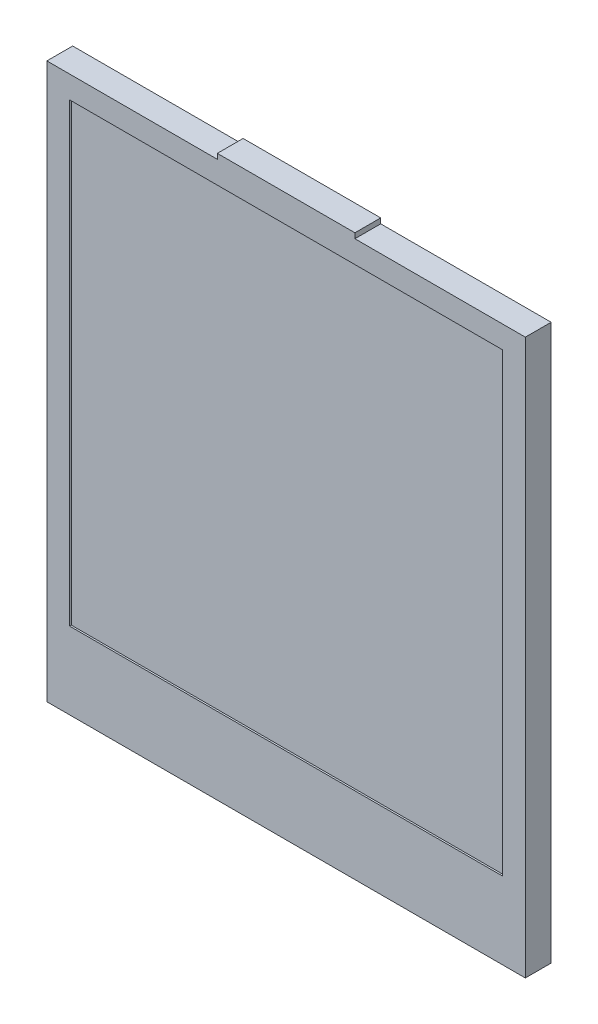
from build123d import *

# Parameters (mm, degrees)
SKETCH1_W           = 25.17
SKETCH1_H           = 26.5
BOSS_EXTRUDE3_DEPTH = 1.5
SKETCH1_4_W         = 25.17
SKETCH1_4_H         = 26.5
BOSS_EXTRUDE4_DEPTH = 1.4


with BuildPart() as part:
    # Sketch1 → Boss-Extrude3 (new body)
    with BuildSketch(Plane.XY):
        Polygon((4, 14.55), (13.91, 14.55), (13.91, -17.72), (-13.91, -17.72), (-13.91, 14.55), (-4, 14.55), (-4, 14.85), (4, 14.85), align=None)
        Rectangle(SKETCH1_W, SKETCH1_H, mode=Mode.SUBTRACT)
    extrude(amount=BOSS_EXTRUDE3_DEPTH)


with BuildPart() as body_2:
    # Sketch1_4 → Boss-Extrude4 (new body)
    with BuildSketch(Plane.XY):
        Rectangle(SKETCH1_4_W, SKETCH1_4_H)
    extrude(amount=BOSS_EXTRUDE4_DEPTH)


solid = Compound([part.part, body_2.part])
